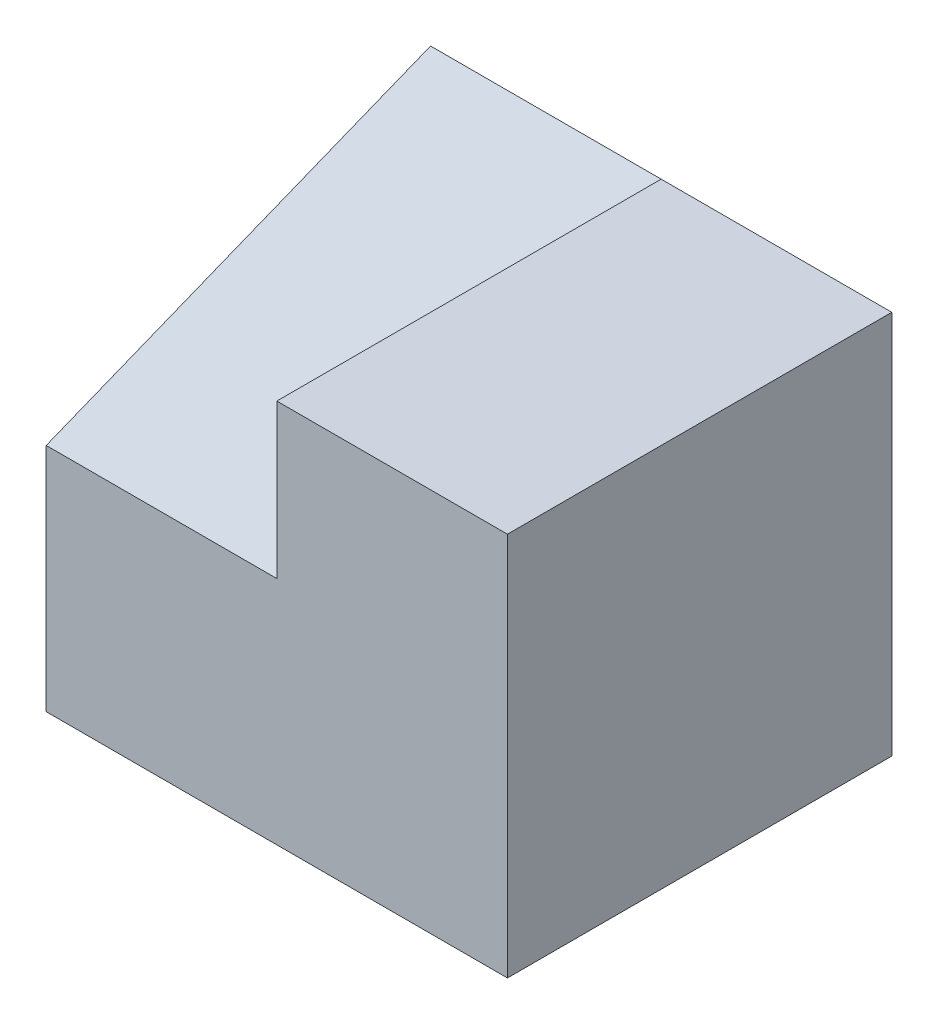
from build123d import *

# Parameters (mm, degrees)
BOSS_EXTRUDE1_DEPTH = 25
BOSS_EXTRUDE2_DEPTH = 15
SKETCH3_W           = 15
SKETCH3_H           = 10
CUT_EXTRUDE1_DEPTH  = 14


with BuildPart() as part:
    # Sketch1 → Boss-Extrude1 (new body)
    with BuildSketch(Plane.XY):
        Polygon((-30, 15), (-15, 15), (-15, 25), (0, 25), (0, 0), (-30, 0), align=None)
    extrude(amount=BOSS_EXTRUDE1_DEPTH)

    # Sketch2 → Boss-Extrude2 (add)
    with BuildSketch(Plane.ZY.offset(15)):
        Polygon((0, 25), (25, 15), (0, 15), align=None)
    extrude(amount=BOSS_EXTRUDE2_DEPTH)

    # Sketch3 → Cut-Extrude1 (cut)
    with BuildSketch(Plane(origin=(0, 0, 0), x_dir=(-1, 0, 0), z_dir=(0, 0, -1))):
        with Locations((22.5, 5)):
            Rectangle(SKETCH3_W, SKETCH3_H)
    extrude(amount=-CUT_EXTRUDE1_DEPTH, mode=Mode.SUBTRACT)


solid = part.part
